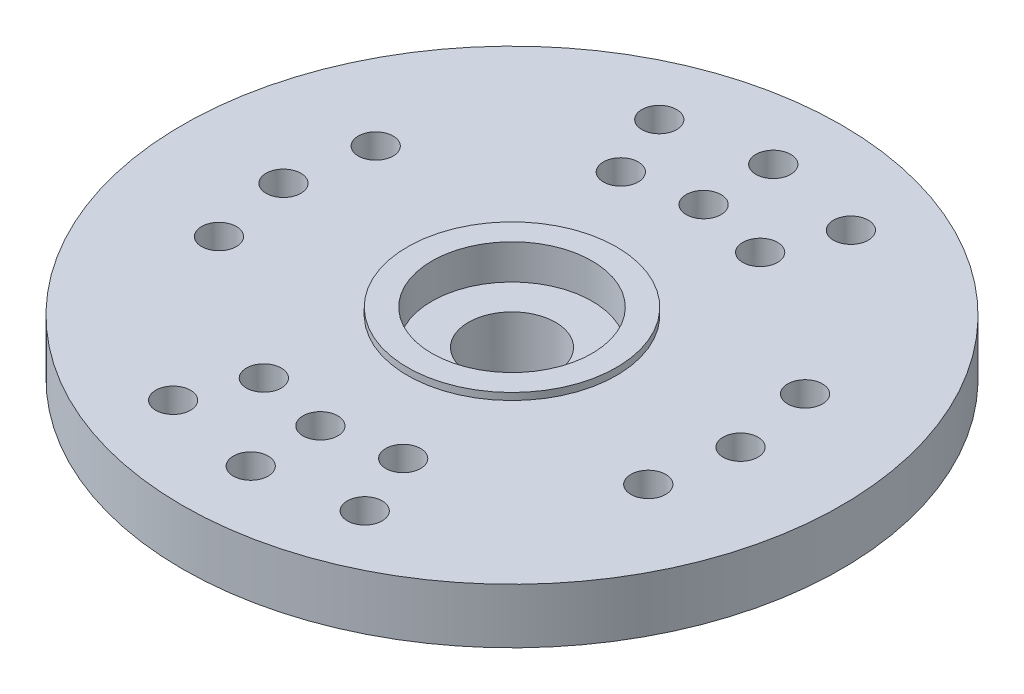
from build123d import *

# Parameters (mm, degrees)
SKETCH2_R      = 2.921
EXTRUDE1_DEPTH = 1.27
SKETCH3_R      = 1.5875
EXTRUDE2_DEPTH = 5.445
SKETCH4_R      = 0.635
EXTRUDE3_DEPTH = 5.191
SKETCH5_R      = 0.635
EXTRUDE4_DEPTH = 5.191


with BuildPart() as part:
    # Sketch1 → Revolve1 (revolve)
    with BuildSketch(Plane.XY):
        Polygon((0, 0), (0, 4.445), (3.81, 4.445), (3.81, 4.191), (12.0142, 4.191), (12.0142, 2.1844), (4.5212, 2.1844), (4.5212, 0), align=None)
    revolve(axis=Axis((0, 0, 0), (0, 1, 0)))

    # Sketch2 → Extrude1 (cut)
    with BuildSketch(Plane(origin=(0, 4.445, 0), x_dir=(1, 0, 0), z_dir=(0, 1, 0))):
        Circle(SKETCH2_R)
    extrude(amount=-EXTRUDE1_DEPTH, mode=Mode.SUBTRACT)

    # Sketch3 → Extrude2 (cut, through all)
    with BuildSketch(Plane.XZ):
        Circle(SKETCH3_R)
    extrude(amount=-EXTRUDE2_DEPTH, mode=Mode.SUBTRACT)

    # Sketch4 → Extrude3 (cut, through all)
    with BuildSketch(Plane(origin=(0, 4.191, 0), x_dir=(1, 0, 0), z_dir=(0, 1, 0))):
        with Locations((0, 6.985)):
            Circle(SKETCH4_R)
        with Locations((-7.825828211, 2.8575)):
            Circle(SKETCH4_R)
        with Locations((-8.3312, 0)):
            Circle(SKETCH4_R)
        with Locations((-7.825828211, -2.8575)):
            Circle(SKETCH4_R)
        with Locations((7.825828211, 2.8575)):
            Circle(SKETCH4_R)
        with Locations((8.3312, 0)):
            Circle(SKETCH4_R)
        with Locations((7.825828211, -2.8575)):
            Circle(SKETCH4_R)
        with Locations((2.54, 6.506813736)):
            Circle(SKETCH4_R)
        with Locations((-2.54, 6.506813736)):
            Circle(SKETCH4_R)
        with Locations((2.54, -6.506813736)):
            Circle(SKETCH4_R)
        with Locations((0, -6.985)):
            Circle(SKETCH4_R)
        with Locations((-2.54, -6.506813736)):
            Circle(SKETCH4_R)
    extrude(amount=-EXTRUDE3_DEPTH, mode=Mode.SUBTRACT)

    # Sketch5 → Extrude4 (cut, through all)
    with BuildSketch(Plane(origin=(0, 4.191, 0), x_dir=(1, 0, 0), z_dir=(0, 1, 0))):
        with Locations((0, 9.525)):
            Circle(SKETCH5_R)
        with Locations((3.4925, 8.861606443)):
            Circle(SKETCH5_R)
        with Locations((-3.4925, 8.861606443)):
            Circle(SKETCH5_R)
        with Locations((3.4925, -8.861606443)):
            Circle(SKETCH5_R)
        with Locations((0, -9.525)):
            Circle(SKETCH5_R)
        with Locations((-3.4925, -8.861606443)):
            Circle(SKETCH5_R)
    extrude(amount=-EXTRUDE4_DEPTH, mode=Mode.SUBTRACT)


solid = part.part
